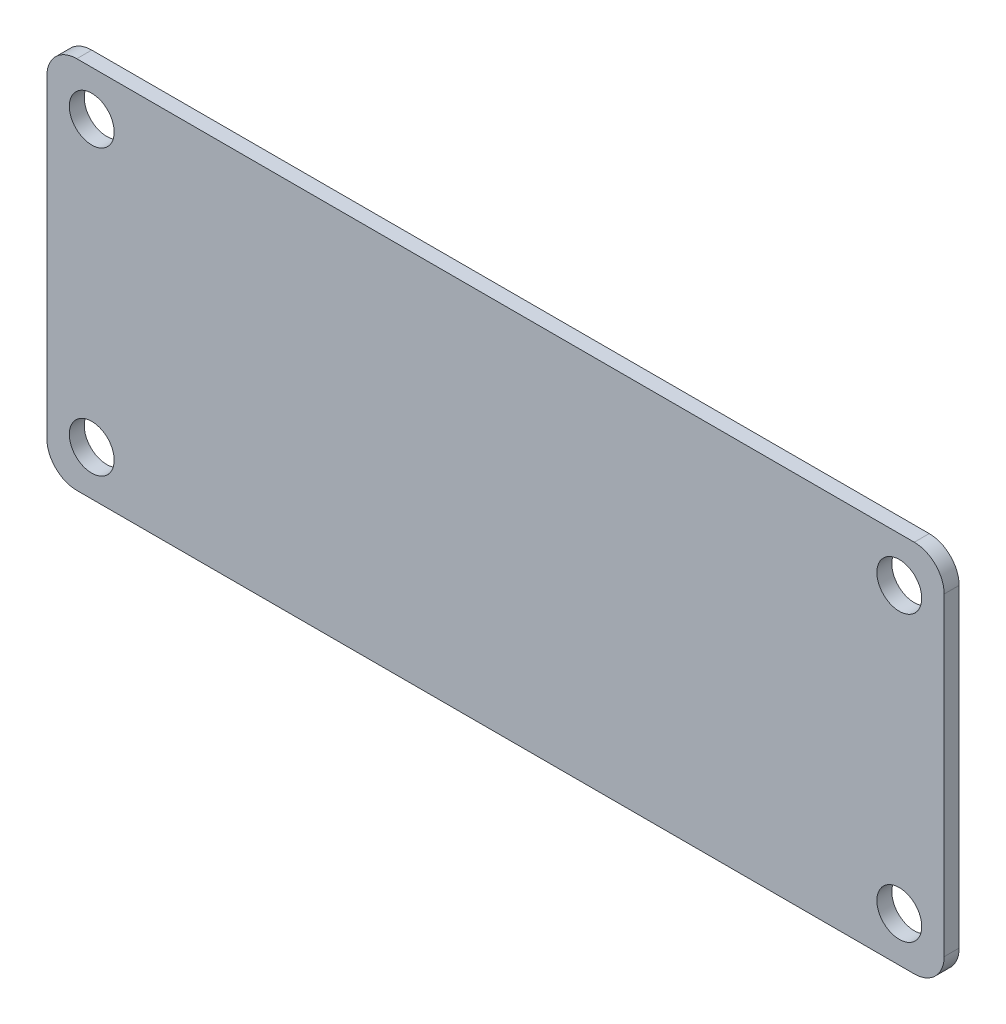
from build123d import *

# Parameters (mm, degrees)
SKETCH_1_W          = 60
SKETCH_1_H          = 25
EXTRUDE_1_DEPTH     = 1
SKETCH_2_R          = 1.5
CUT_EXTRUDE_1_DEPTH = 2
FILLET_1_R          = 2


with BuildPart() as part:
    # ｽｹｯﾁ1 → ﾎﾞｽ - 押し出し1 (new body)
    with BuildSketch(Plane.XY):
        Rectangle(SKETCH_1_W, SKETCH_1_H)
    extrude(amount=EXTRUDE_1_DEPTH)

    # ｽｹｯﾁ2 → ｶｯﾄ - 押し出し1 (cut, through all)
    with BuildSketch(Plane.XY.offset(1)):
        with Locations((-27, 9.5)):
            Circle(SKETCH_2_R)
        with Locations((27, 9.5)):
            Circle(SKETCH_2_R)
        with Locations((-27, -9.5)):
            Circle(SKETCH_2_R)
        with Locations((27, -9.5)):
            Circle(SKETCH_2_R)
    extrude(amount=-CUT_EXTRUDE_1_DEPTH, mode=Mode.SUBTRACT)

    # ﾌｨﾚｯﾄ1
    fillet_1_edges = [part.edges().sort_by_distance(p)[0] for p in [
        (-30, 12.5, 0.5),
        (30, 12.5, 0.5),
        (30, -12.5, 0.5),
        (-30, -12.5, 0.5),
    ]]
    fillet(fillet_1_edges, radius=FILLET_1_R)


solid = part.part
